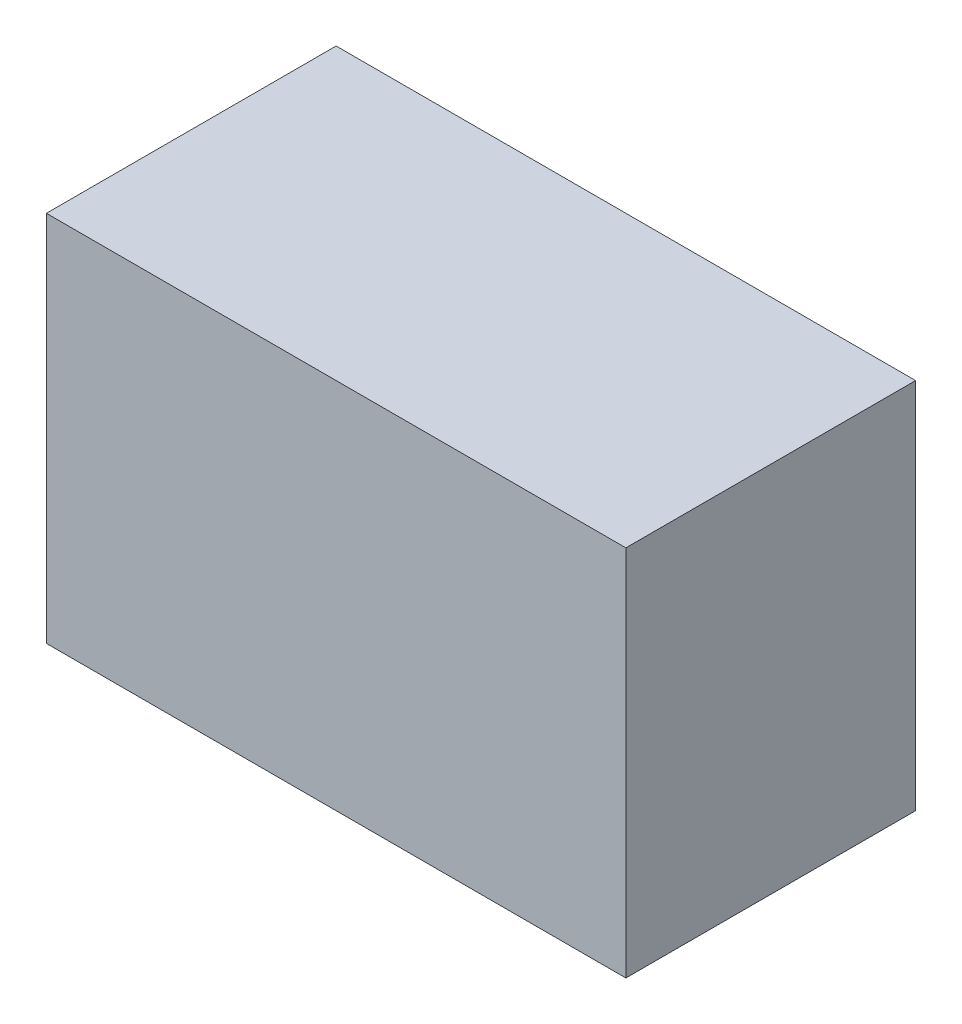
from build123d import *

# Parameters (mm, degrees)
SKETCH1_W           = 1400
SKETCH1_H           = 700
BOSS_EXTRUDE1_DEPTH = 900


with BuildPart() as part:
    # Sketch1 → Boss-Extrude1 (new body)
    with BuildSketch(Plane(origin=(0, 0, 0), x_dir=(1, 0, 0), z_dir=(0, 1, 0))):
        Rectangle(SKETCH1_W, SKETCH1_H)
    extrude(amount=-BOSS_EXTRUDE1_DEPTH)


solid = part.part
